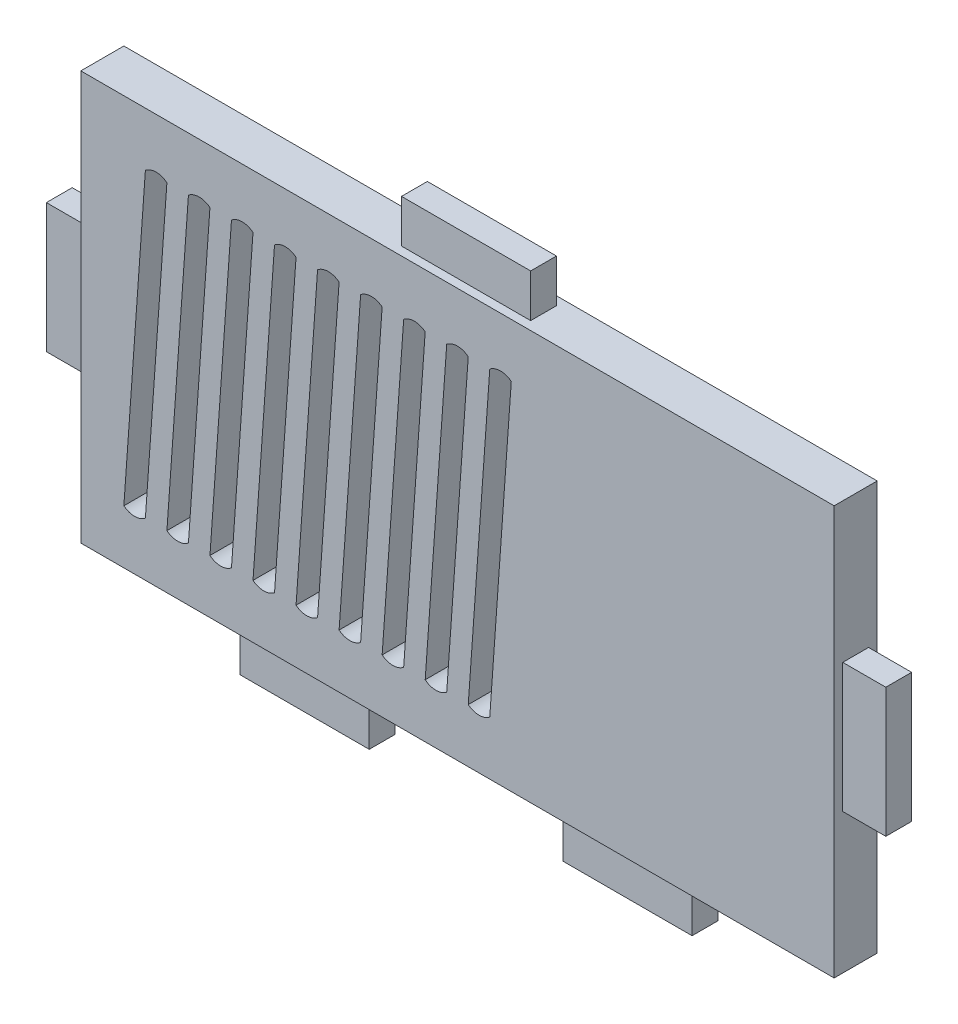
from build123d import *

# Parameters (mm, degrees)
ESBO_O1_W                = 175
ESBO_O1_H                = 95
RESSALTO_EXTRUS_O1_DEPTH = 10
ESBO_O2_W                = 6
ESBO_O2_H                = 30
RESSALTO_EXTRUS_O2_DEPTH = 10
ESBO_O3_W                = 6
ESBO_O3_H                = 30
RESSALTO_EXTRUS_O3_DEPTH = 10
ESBO_O4_W                = 30
ESBO_O4_H                = 6
RESSALTO_EXTRUS_O4_DEPTH = 10
ESBO_O5_W                = 30
ESBO_O5_H                = 6
RESSALTO_EXTRUS_O5_DEPTH = 10
CORTE_EXTRUS_O1_DEPTH    = 10


with BuildPart() as part:
    # Esboço1 → Ressalto-extrusão1 (new body)
    with BuildSketch(Plane.XY):
        Rectangle(ESBO_O1_W, ESBO_O1_H)
    extrude(amount=RESSALTO_EXTRUS_O1_DEPTH)

    # Esboço2 → Ressalto-extrusão2 (add)
    with BuildSketch(Plane.ZY.offset(87.5)):
        with Locations((5, 0)):
            Rectangle(ESBO_O2_W, ESBO_O2_H)
    extrude(amount=RESSALTO_EXTRUS_O2_DEPTH)

    # Esboço3 → Ressalto-extrusão3 (add)
    with BuildSketch(Plane(origin=(87.5, 0, 0), x_dir=(0, 0, -1), z_dir=(1, 0, 0))):
        with Locations((-5, 0)):
            Rectangle(ESBO_O3_W, ESBO_O3_H)
    extrude(amount=RESSALTO_EXTRUS_O3_DEPTH)

    # Esboço4 → Ressalto-extrusão4 (add)
    with BuildSketch(Plane.XZ.offset(47.5)):
        with Locations((37.5, 5)):
            Rectangle(ESBO_O4_W, ESBO_O4_H)
        with Locations((-37.5, 5)):
            Rectangle(ESBO_O4_W, ESBO_O4_H)
    extrude(amount=RESSALTO_EXTRUS_O4_DEPTH)

    # Esboço5 → Ressalto-extrusão5 (add)
    with BuildSketch(Plane(origin=(0, 47.5, 0), x_dir=(1, 0, 0), z_dir=(0, 1, 0))):
        with Locations((0, -5)):
            Rectangle(ESBO_O5_W, ESBO_O5_H)
    extrude(amount=RESSALTO_EXTRUS_O5_DEPTH)

    # Esboço6 → Corte-extrusão1 (cut)
    with BuildSketch(Plane.XY.offset(10)):
        with BuildLine():
            Line((-77.5, -35), (-72.5, 35))
            ThreePointArc((-72.5, 35), (-70, 35.877501001), (-67.5, 35))
            Line((-67.5, 35), (-72.5, -35))
            ThreePointArc((-72.5, -35), (-75, -35.877501001), (-77.5, -35))
        make_face()
        with BuildLine():
            Line((-62.5, -35), (-57.5, 35))
            ThreePointArc((-57.5, 35), (-60, 35.877501001), (-62.5, 35))
            Line((-62.5, 35), (-67.5, -35))
            ThreePointArc((-67.5, -35), (-65, -35.877501001), (-62.5, -35))
        make_face()
        with BuildLine():
            Line((-52.5, -35), (-47.5, 35))
            ThreePointArc((-47.5, 35), (-50, 35.877501001), (-52.5, 35))
            Line((-52.5, 35), (-57.5, -35))
            ThreePointArc((-57.5, -35), (-55, -35.877501001), (-52.5, -35))
        make_face()
        with BuildLine():
            Line((-42.5, -35), (-37.5, 35))
            ThreePointArc((-37.5, 35), (-40, 35.877501001), (-42.5, 35))
            Line((-42.5, 35), (-47.5, -35))
            ThreePointArc((-47.5, -35), (-45, -35.877501001), (-42.5, -35))
        make_face()
        with BuildLine():
            Line((-32.5, -35), (-27.5, 35))
            ThreePointArc((-27.5, 35), (-30, 35.877501001), (-32.5, 35))
            Line((-32.5, 35), (-37.5, -35))
            ThreePointArc((-37.5, -35), (-35, -35.877501001), (-32.5, -35))
        make_face()
        with BuildLine():
            Line((-22.5, -35), (-17.5, 35))
            ThreePointArc((-17.5, 35), (-20, 35.877501001), (-22.5, 35))
            Line((-22.5, 35), (-27.5, -35))
            ThreePointArc((-27.5, -35), (-25, -35.877501001), (-22.5, -35))
        make_face()
        with BuildLine():
            Line((-12.5, -35), (-7.5, 35))
            ThreePointArc((-7.5, 35), (-10, 35.877501001), (-12.5, 35))
            Line((-12.5, 35), (-17.5, -35))
            ThreePointArc((-17.5, -35), (-15, -35.877501001), (-12.5, -35))
        make_face()
        with BuildLine():
            Line((-2.5, -35), (2.5, 35))
            ThreePointArc((2.5, 35), (0, 35.877501001), (-2.5, 35))
            Line((-2.5, 35), (-7.5, -35))
            ThreePointArc((-7.5, -35), (-5, -35.877501001), (-2.5, -35))
        make_face()
        with BuildLine():
            Line((7.5, -35), (12.5, 35))
            ThreePointArc((12.5, 35), (10, 35.877501001), (7.5, 35))
            Line((7.5, 35), (2.5, -35))
            ThreePointArc((2.5, -35), (5, -35.877501001), (7.5, -35))
        make_face()
    extrude(amount=-CORTE_EXTRUS_O1_DEPTH, mode=Mode.SUBTRACT)


solid = part.part
